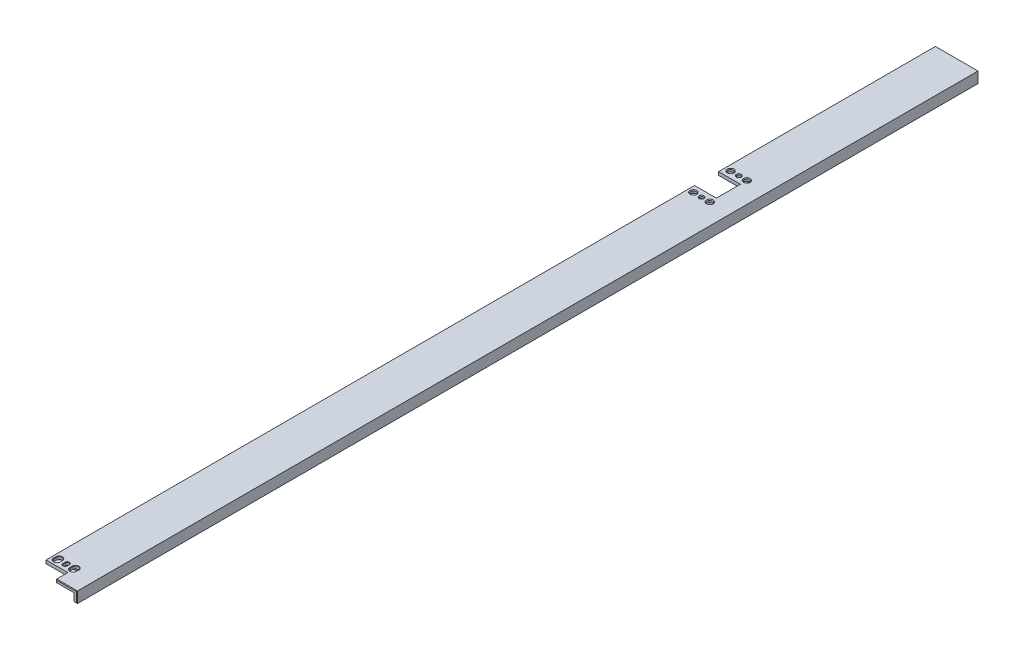
from build123d import *

# Parameters (mm, degrees)
EXTRUDE1_DEPTH                 = 10
EXTRUDE2_DEPTH                 = 7
SKETCH5_W                      = 26
SKETCH5_H                      = 15
EXTRUDE3_DEPTH                 = 7
SKETCH16_W                     = 6
SKETCH16_H                     = 22
SKETCH16_H_2                   = 10.7
EXTRUDE8_DEPTH                 = 7
F_8_CLEARANCE_HOLE1_AT_2_COUNT = 2
F_8_CLEARANCE_HOLE1_AT_2_PITCH = 15
F_8_CLEARANCE_HOLE2_AT_2_COUNT = 2
F_8_CLEARANCE_HOLE2_AT_2_PITCH = 15
EXTRUDE6_DEPTH                 = 4
SKETCH15_W                     = 12
SKETCH15_H                     = 170.1
EXTRUDE7_DEPTH                 = 7
FILLET1_R                      = 3.175
CHAMFER1_SIZE                  = 0.5
CHAMFER2_SIZE                  = 0.3
FILLET4_R                      = 3
FILLET3_R                      = 0.5


with BuildPart() as part:
    # Sketch1 → Extrude1 (new body)
    with BuildSketch(Plane(origin=(0, 0, 0), x_dir=(1, 0, 0), z_dir=(0, 1, 0))):
        Polygon((-126.1, 2198), (-165.1, 2198), (-165.1, 1998.9), (-145.1, 1998.9), (-145.1, 1988.2), (-145.1, 1987.6), (-145.1, 1976.9), (-165.1, 1976.9), (-165.1, 1382.9), (-145.1, 1382.9), (-145.1, 1372.2), (-126.1, 1372.2), align=None)
    extrude(amount=-EXTRUDE1_DEPTH)

    # Sketch4 → Extrude2 (cut)
    with BuildSketch(Plane.XZ.offset(10)):
        Polygon((-139.1, -1372.2), (-129.1, -1372.2), (-129.1, -2198), (-139.1, -2198), (-139.1, -1946.9), (-165.1, -1946.9), (-165.1, -1412.9), (-139.1, -1412.9), align=None)
    extrude(amount=-EXTRUDE2_DEPTH, mode=Mode.SUBTRACT)

    # Sketch5 → Extrude3 (cut)
    with BuildSketch(Plane.XZ.offset(10)):
        with Locations((-152.1, -1390.4)):
            Rectangle(SKETCH5_W, SKETCH5_H)
        with Locations((-152.1, -2006.4)):
            Rectangle(SKETCH5_W, SKETCH5_H)
        with Locations((-152.1, -1969.4)):
            Rectangle(SKETCH5_W, SKETCH5_H)
    extrude(amount=-EXTRUDE3_DEPTH, mode=Mode.SUBTRACT)

    # Sketch16 → Extrude8 (cut)
    with BuildSketch(Plane.XZ.offset(10)):
        with Locations((-142.1, -1987.9)):
            Rectangle(SKETCH16_W, SKETCH16_H)
        with Locations((-142.1, -1377.55)):
            Rectangle(SKETCH16_W, SKETCH16_H_2)
    extrude(amount=-EXTRUDE8_DEPTH, mode=Mode.SUBTRACT)

    # Sketch9 → 1/8 (0.125) Diameter Hole1 (revolve, cut)
    with BuildSketch(Plane(origin=(-152.6, -3, -2004.9), x_dir=(0, 0, -1), z_dir=(1, 0, 0))):
        Polygon((0, 0), (0, 3), (2.2479, 3), (1.6129, 2.365), (1.6129, 0.635), (2.2479, 0), align=None)
    revolve(axis=Axis((-152.6, -9.35, -2004.9), (0, 1, 0)), mode=Mode.SUBTRACT)

    # Sketch17 → 1/8 (0.125) Diameter Hole2 (revolve, cut)
    with BuildSketch(Plane(origin=(-152.6, -3, -1970.9), x_dir=(0, 0, -1), z_dir=(1, 0, 0))):
        Polygon((0, 0), (0, 3), (2.2479, 3), (1.6129, 2.365), (1.6129, 0.635), (2.2479, 0), align=None)
    revolve(axis=Axis((-152.6, -9.35, -1970.9), (0, 1, 0)), mode=Mode.SUBTRACT)

    # Sketch10 → #8 Clearance Hole1 (revolve, cut)
    with BuildSketch(Plane(origin=(-160.1, -3, -1970.9), x_dir=(0, 0, -1), z_dir=(1, 0, 0))):
        Polygon((0, 0), (0, 3), (3.0861, 3), (2.45745, 2.37135), (2.45745, 0.635), (3.09245, 0), align=None)
    f_8_clearance_hole1 = revolve(axis=Axis((-160.1, -9.35, -1970.9), (0, 1, 0)), mode=Mode.SUBTRACT)

    # #8 Clearance Hole1 at 2: #8 Clearance Hole1 ×2
    with Locations(*[(i * F_8_CLEARANCE_HOLE1_AT_2_PITCH, 0, 0) for i in range(1, F_8_CLEARANCE_HOLE1_AT_2_COUNT)]):
        add(f_8_clearance_hole1, mode=Mode.SUBTRACT)

    # Sketch14 → #8 Clearance Hole2 (revolve, cut)
    with BuildSketch(Plane(origin=(-160.1, -3, -2004.9), x_dir=(0, 0, -1), z_dir=(1, 0, 0))):
        Polygon((0, 0), (0, 3), (3.0861, 3), (2.45745, 2.37135), (2.45745, 0.635), (3.09245, 0), align=None)
    f_8_clearance_hole2 = revolve(axis=Axis((-160.1, -9.35, -2004.9), (0, 1, 0)), mode=Mode.SUBTRACT)

    # #8 Clearance Hole2 at 2: #8 Clearance Hole2 ×2
    with Locations(*[(i * F_8_CLEARANCE_HOLE2_AT_2_PITCH, 0, 0) for i in range(1, F_8_CLEARANCE_HOLE2_AT_2_COUNT)]):
        add(f_8_clearance_hole2, mode=Mode.SUBTRACT)

    # Sketch12 → Extrude6 (cut, through all)
    with BuildSketch(Plane.XZ.offset(3)):
        with BuildLine():
            Line((-154.251, -1387.9), (-154.251, -1389.9))
            ThreePointArc((-154.251, -1389.9), (-152.6, -1391.551), (-150.949, -1389.9))
            Line((-150.949, -1389.9), (-150.949, -1387.9))
            ThreePointArc((-150.949, -1387.9), (-152.6, -1386.249), (-154.251, -1387.9))
        make_face()
        with BuildLine():
            Line((-162.85, -1389.9), (-162.85, -1387.9))
            ThreePointArc((-162.85, -1387.9), (-160.1, -1385.15), (-157.35, -1387.9))
            Line((-157.35, -1387.9), (-157.35, -1389.9))
            ThreePointArc((-157.35, -1389.9), (-160.1, -1392.65), (-162.85, -1389.9))
        make_face()
        with BuildLine():
            Line((-147.85, -1389.9), (-147.85, -1387.9))
            ThreePointArc((-147.85, -1387.9), (-145.1, -1385.15), (-142.35, -1387.9))
            Line((-142.35, -1387.9), (-142.35, -1389.9))
            ThreePointArc((-142.35, -1389.9), (-145.1, -1392.65), (-147.85, -1389.9))
        make_face()
    extrude(amount=-EXTRUDE6_DEPTH, mode=Mode.SUBTRACT)

    # Sketch15 → Extrude7 (cut)
    with BuildSketch(Plane.XZ.offset(10)):
        with Locations((-152.1, -2105.95)):
            Rectangle(SKETCH15_W, SKETCH15_H)
    extrude(amount=-EXTRUDE7_DEPTH, mode=Mode.SUBTRACT)

    # Fillet1
    fillet1_edges = [part.edges().sort_by_distance(p)[0] for p in [
        (-146.1, -6.5, -2020.9),
        (-158.1, -6.5, -2020.9),
        (-158.1, -6.5, -2191),
        (-146.1, -6.5, -2191),
    ]]
    fillet(fillet1_edges, radius=FILLET1_R)

    # Chamfer1
    chamfer1_edges = [part.edges().sort_by_distance(p)[0] for p in [
        (-129.1, -6.5, -2198),
        (-126.1, -5, -2198),
        (-139.1, -6.5, -2198),
        (-134.1, -3, -2198),
        (-145.6, 0, -2198),
        (-165.1, -5, -2198),
        (-152.1, -10, -2198),
        (-145.1, -1.5, -1372.2),
        (-137.1, -3, -1372.2),
        (-135.6, 0, -1372.2),
        (-126.1, -5, -1372.2),
        (-127.6, -10, -1372.2),
        (-129.1, -6.5, -1372.2),
    ]]
    chamfer(chamfer1_edges, length=CHAMFER1_SIZE)

    # Chamfer2
    chamfer2_edges = [part.edges().sort_by_distance(p)[0] for p in [
        (-152.6, 0, -1386.249),
        (-150.949, 0, -1388.9),
        (-152.6, 0, -1391.551),
        (-154.251, 0, -1388.9),
        (-152.6, -3, -1386.249),
        (-154.251, -3, -1388.9),
        (-152.6, -3, -1391.551),
        (-150.949, -3, -1388.9),
        (-160.1, 0, -1385.15),
        (-157.35, 0, -1388.9),
        (-160.1, 0, -1392.65),
        (-162.85, 0, -1388.9),
        (-160.1, -3, -1385.15),
        (-162.85, -3, -1388.9),
        (-160.1, -3, -1392.65),
        (-157.35, -3, -1388.9),
        (-145.1, 0, -1385.15),
        (-142.35, 0, -1388.9),
        (-145.1, 0, -1392.65),
        (-147.85, 0, -1388.9),
        (-145.1, -3, -1385.15),
        (-147.85, -3, -1388.9),
        (-145.1, -3, -1392.65),
        (-142.35, -3, -1388.9),
    ]]
    chamfer(chamfer2_edges, length=CHAMFER2_SIZE)

    # Fillet4
    fillet4_edges = [part.edges().sort_by_distance(p)[0] for p in [
        (-139.1, -6.5, -1412.9),
        (-139.1, -6.5, -1946.9),
        (-139.1, -6.5, -1397.9),
        (-139.1, -6.5, -2013.9),
        (-139.1, -6.5, -1961.9),
    ]]
    fillet(fillet4_edges, radius=FILLET4_R)

    # Fillet3
    fillet3_edges = [part.edges().sort_by_distance(p)[0] for p in [
        (-146.1, -3, -2105.95),
        (-152.1, -3, -2191),
        (-152.1, -3, -2020.9),
        (-158.1, -3, -2105.95),
        (-147.02993597, -3, -2021.82993597),
        (-157.17006403, -3, -2021.82993597),
        (-157.17006403, -3, -2190.07006403),
        (-147.02993597, -3, -2190.07006403),
        (-129.1, -3, -1785.1),
        (-139.1, -3, -2107.2),
        (-153.6, -3, -1961.9),
        (-139.1, -3, -1954.4),
        (-153.6, -3, -1412.9),
        (-139.1, -3, -1405.4),
        (-139.978679656, -3, -2014.778679656),
        (-139.978679656, -3, -1961.021320344),
        (-139.978679656, -3, -1947.778679656),
        (-139.978679656, -3, -1412.021320344),
        (-139.978679656, -3, -1398.778679656),
        (-153.6, -3, -1946.9),
        (-153.6, -3, -1397.9),
        (-153.6, -3, -2013.9),
    ]]
    fillet(fillet3_edges, radius=FILLET3_R)


solid = part.part
